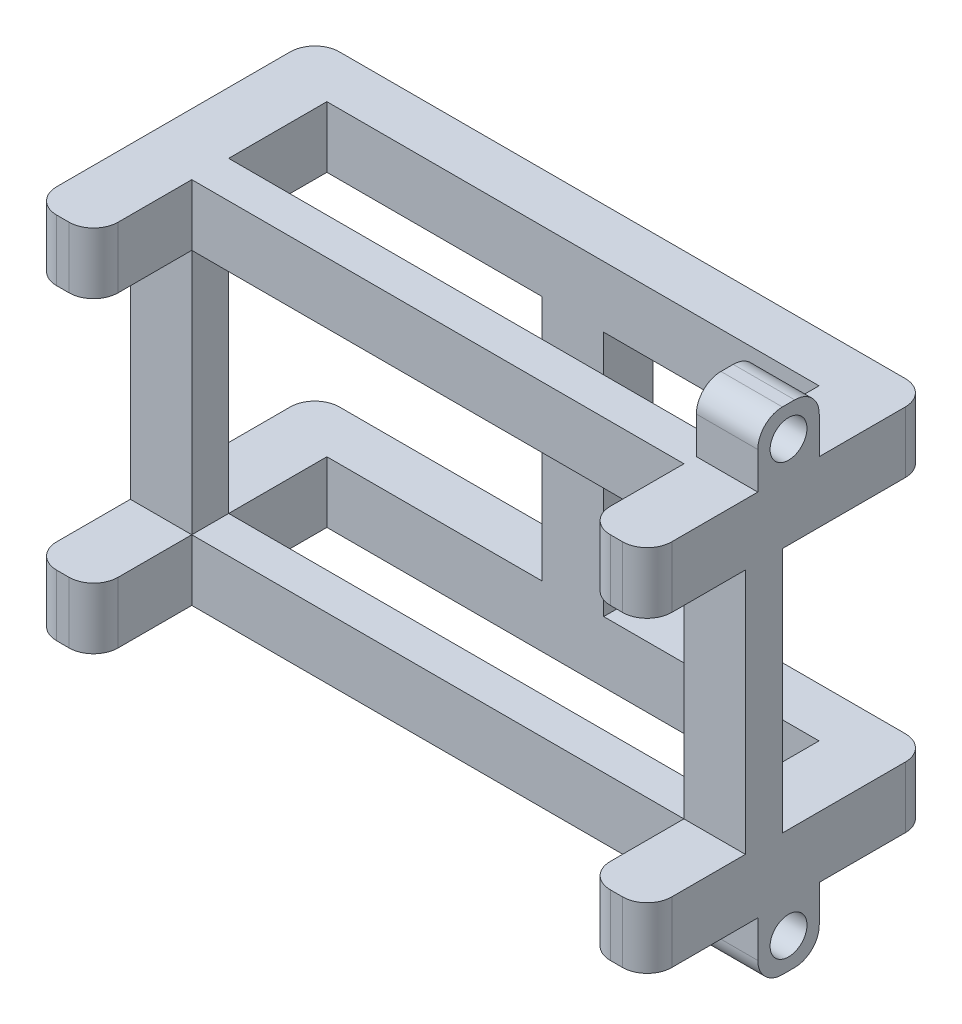
from build123d import *

# Parameters (mm, degrees)
SKETCH1_W           = 50.04
SKETCH1_H           = 30.04
SKETCH1_W_2         = 40.04
SKETCH1_H_2         = 20.04
SKETCH1_W_3         = 5
BOSS_EXTRUDE2_DEPTH = 28
SKETCH2_W           = 50.04
SKETCH2_H           = 30.04
SKETCH2_W_2         = 17.52
SKETCH2_H_2         = 20.04
BOSS_EXTRUDE3_DEPTH = 5
SKETCH3_W           = 5
SKETCH3_H           = 20.04
CUT_EXTRUDE1_DEPTH  = 27
SKETCH4_W           = 5
SKETCH4_H           = 20.04
CUT_EXTRUDE3_DEPTH  = 27
SKETCH5_W           = 40.04
SKETCH5_H           = 28.980890752
CUT_EXTRUDE4_DEPTH  = 47
SKETCH6_W           = 5
SKETCH6_H           = 5
BOSS_EXTRUDE4_DEPTH = 45
CUT_EXTRUDE5_DEPTH  = 66
SKETCH8_W           = 5
SKETCH8_H           = 3
BOSS_EXTRUDE5_DEPTH = 29
SKETCH9_W           = 40.04
SKETCH9_H           = 5
CUT_EXTRUDE6_DEPTH  = 51
SKETCH10_W          = 40.04
SKETCH10_H          = 3
BOSS_EXTRUDE6_DEPTH = 5
SKETCH12_W          = 40.04
SKETCH12_H          = 3
BOSS_EXTRUDE7_DEPTH = 5
FILLET1_R           = 2
SKETCH13_W          = 23
SKETCH13_H          = 0.02
CUT_EXTRUDE7_DEPTH  = 87
SKETCH14_W          = 5
SKETCH14_H          = 5
SKETCH14_R          = 1.5
BOSS_EXTRUDE8_DEPTH = 5
FILLET2_R           = 2


with BuildPart() as part:
    # Sketch1 → Boss-Extrude2 (new body)
    with BuildSketch(Plane.XY):
        with Locations((20.02, -10.02)):
            Rectangle(SKETCH1_W, SKETCH1_H)
        with Locations((20.02, -10.02)):
            Rectangle(SKETCH1_W_2, SKETCH1_H_2, mode=Mode.SUBTRACT)
        with Locations((20.02, -10.02)):
            Rectangle(SKETCH1_W_3, SKETCH1_H_2)
    extrude(amount=BOSS_EXTRUDE2_DEPTH)

    # Sketch2 → Boss-Extrude3 (add)
    with BuildSketch(Plane(origin=(0, 0, 0), x_dir=(-1, 0, 0), z_dir=(0, 0, -1))):
        with Locations((-20.02, -10.02)):
            Rectangle(SKETCH2_W, SKETCH2_H)
        with Locations((-31.28, -10.02)):
            Rectangle(SKETCH2_W_2, SKETCH2_H_2, mode=Mode.SUBTRACT)
        with Locations((-8.76, -10.02)):
            Rectangle(SKETCH2_W_2, SKETCH2_H_2, mode=Mode.SUBTRACT)
    extrude(amount=BOSS_EXTRUDE3_DEPTH)

    # Sketch3 → Cut-Extrude1 (cut)
    with BuildSketch(Plane.XY.offset(28)):
        with Locations((20.02, -10.02)):
            Rectangle(SKETCH3_W, SKETCH3_H)
    extrude(amount=-CUT_EXTRUDE1_DEPTH, mode=Mode.SUBTRACT)

    # Sketch4 → Cut-Extrude3 (cut)
    with BuildSketch(Plane(origin=(0, 0, -5), x_dir=(-1, 0, 0), z_dir=(0, 0, -1))):
        with Locations((-42.54, -10.02)):
            Rectangle(SKETCH4_W, SKETCH4_H)
        with Locations((2.5, -10.02)):
            Rectangle(SKETCH4_W, SKETCH4_H)
    extrude(amount=-CUT_EXTRUDE3_DEPTH, mode=Mode.SUBTRACT)

    # Sketch5 → Cut-Extrude4 (cut)
    with BuildSketch(Plane(origin=(0, 5, 0), x_dir=(1, 0, 0), z_dir=(0, 1, 0))):
        with Locations((20.02, -13.509554624)):
            Rectangle(SKETCH5_W, SKETCH5_H)
    extrude(amount=-CUT_EXTRUDE4_DEPTH, mode=Mode.SUBTRACT)

    # Sketch6 → Boss-Extrude4 (add)
    with BuildSketch(Plane(origin=(0, 0, 0), x_dir=(0, 0, -1), z_dir=(1, 0, 0))):
        with Locations((-11.5, 2.5)):
            Rectangle(SKETCH6_W, SKETCH6_H)
        with Locations((-11.5, -22.54)):
            Rectangle(SKETCH6_W, SKETCH6_H)
    extrude(amount=BOSS_EXTRUDE4_DEPTH)

    # Sketch7 → Cut-Extrude5 (cut)
    with BuildSketch(Plane(origin=(45.04, 0, 0), x_dir=(0, 0, -1), z_dir=(1, 0, 0))):
        Polygon((-28, -25.04), (-18, -25.04), (-18, -20.04), (-22, -20.04), (-22, 0), (-18, 0), (-18, 5), (-28, 5), align=None)
    extrude(amount=-CUT_EXTRUDE5_DEPTH, mode=Mode.SUBTRACT)

    # Sketch8 → Boss-Extrude5 (add)
    with BuildSketch(Plane.XZ.offset(25.04)):
        with Locations((-2.5, 8.509554624)):
            Rectangle(SKETCH8_W, SKETCH8_H)
        with Locations((42.54, 8.509554624)):
            Rectangle(SKETCH8_W, SKETCH8_H)
    extrude(amount=-BOSS_EXTRUDE5_DEPTH)

    # Sketch9 → Cut-Extrude6 (cut)
    with BuildSketch(Plane(origin=(0, -25.04, 0), x_dir=(-1, 0, 0), z_dir=(0, -1, 0))):
        with Locations((-20.02, -11.5)):
            Rectangle(SKETCH9_W, SKETCH9_H)
    extrude(amount=-CUT_EXTRUDE6_DEPTH, mode=Mode.SUBTRACT)

    # Sketch10 → Boss-Extrude6 (add)
    with BuildSketch(Plane.XZ.offset(25.04)):
        with Locations((20.02, 8.509554624)):
            Rectangle(SKETCH10_W, SKETCH10_H)
    extrude(amount=-BOSS_EXTRUDE6_DEPTH)

    # Sketch12 → Boss-Extrude7 (add)
    with BuildSketch(Plane(origin=(0, 5, 0), x_dir=(1, 0, 0), z_dir=(0, 1, 0))):
        with Locations((20.02, -8.509554624)):
            Rectangle(SKETCH12_W, SKETCH12_H)
    extrude(amount=-BOSS_EXTRUDE7_DEPTH)

    # Fillet1
    fillet1_edges = [part.edges().sort_by_distance(p)[0] for p in [
        (40.04, 2.5, 18),
        (0, 2.5, 18),
        (-5, 2.5, 18),
        (40.04, -22.54, 18),
        (0, -22.54, 18),
        (-5, -22.54, 18),
        (45.04, -22.54, 18),
        (45.04, 2.5, 18),
        (45.04, 2.5, -5),
        (-5, -22.54, -5),
        (45.04, -22.54, -5),
        (-5, 2.5, -5),
    ]]
    fillet(fillet1_edges, radius=FILLET1_R)

    # Sketch13 → Cut-Extrude7 (cut)
    with BuildSketch(Plane(origin=(45.04, 0, 0), x_dir=(0, 0, -1), z_dir=(1, 0, 0))):
        with Locations((-6.5, -25.03)):
            Rectangle(SKETCH13_W, SKETCH13_H)
        with Locations((-6.5, 4.99)):
            Rectangle(SKETCH13_W, SKETCH13_H)
    extrude(amount=-CUT_EXTRUDE7_DEPTH, mode=Mode.SUBTRACT)

    # Sketch14 → Boss-Extrude8 (add)
    with BuildSketch(Plane(origin=(45.04, 0, 0), x_dir=(0, 0, -1), z_dir=(1, 0, 0))):
        with Locations((-6.5, -27.52)):
            Rectangle(SKETCH14_W, SKETCH14_H)
        with Locations((-6.5, -27.52)):
            Circle(SKETCH14_R, mode=Mode.SUBTRACT)
        with Locations((-6.5, 7.48)):
            Rectangle(SKETCH14_W, SKETCH14_H)
        with Locations((-6.5, 7.48)):
            Circle(SKETCH14_R, mode=Mode.SUBTRACT)
    extrude(amount=-BOSS_EXTRUDE8_DEPTH)

    # Fillet2
    fillet2_edges = [part.edges().sort_by_distance(p)[0] for p in [
        (42.54, -30.02, 4),
        (42.54, -30.02, 9),
        (42.54, 9.98, 4),
        (42.54, 9.98, 9),
    ]]
    fillet(fillet2_edges, radius=FILLET2_R)


solid = part.part
